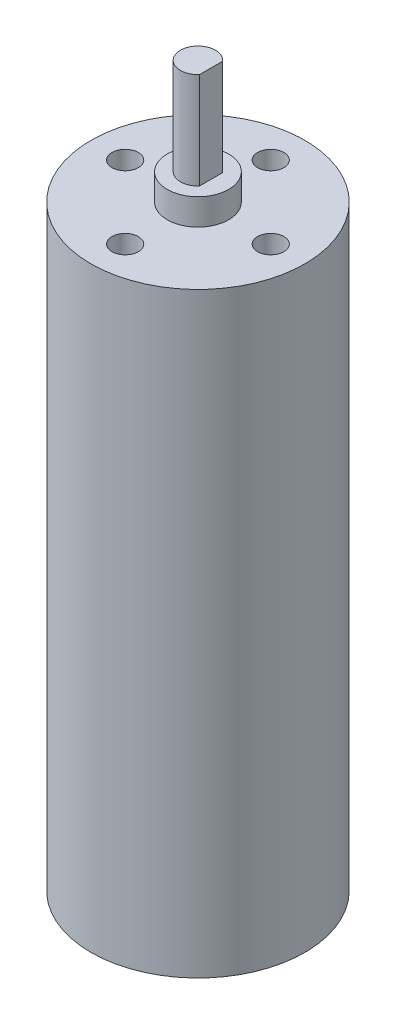
from build123d import *

# Parameters (mm, degrees)
SKETCH1_R           = 12.2
BOSS_EXTRUDE1_DEPTH = 47
SKETCH2_R           = 12.2
BOSS_EXTRUDE3_DEPTH = 21
SKETCH3_R           = 3.5
BOSS_EXTRUDE4_DEPTH = 3
BOSS_EXTRUDE5_DEPTH = 11
SKETCH6_R           = 1
CUT_EXTRUDE1_DEPTH  = 10
SKETCH5_W           = 0.205128205
SKETCH5_H           = 2
SKETCH5_W_2         = 0.820512821
SKETCH5_H_2         = 0.205128205
CUT_EXTRUDE2_DEPTH  = 4
SKETCH7_R           = 1.5
CUT_EXTRUDE3_DEPTH  = 10


with BuildPart() as part:
    # Sketch1 → Boss-Extrude1 (new body)
    with BuildSketch(Plane(origin=(0, 0, 0), x_dir=(1, 0, 0), z_dir=(0, 1, 0))):
        Circle(SKETCH1_R)
    extrude(amount=BOSS_EXTRUDE1_DEPTH)

    # Sketch2 → Boss-Extrude3 (add)
    with BuildSketch(Plane(origin=(0, 47, 0), x_dir=(1, 0, 0), z_dir=(0, 1, 0))):
        Circle(SKETCH2_R)
    extrude(amount=BOSS_EXTRUDE3_DEPTH)

    # Sketch3 → Boss-Extrude4 (add)
    with BuildSketch(Plane(origin=(0, 68, 0), x_dir=(1, 0, 0), z_dir=(0, 1, 0))):
        Circle(SKETCH3_R)
    extrude(amount=BOSS_EXTRUDE4_DEPTH)

    # Sketch4 → Boss-Extrude5 (add)
    with BuildSketch(Plane(origin=(0, 71, 0), x_dir=(1, 0, 0), z_dir=(0, 1, 0))):
        with BuildLine():
            Line((1.5, 1.322875656), (1.5, -1.322875656))
            ThreePointArc((1.5, -1.322875656), (-2, 0), (1.5, 1.322875656))
        make_face()
    extrude(amount=BOSS_EXTRUDE5_DEPTH)

    # Sketch6 → Cut-Extrude1 (cut)
    with BuildSketch(Plane.XZ):
        with Locations((8.05, -5.4)):
            Circle(SKETCH6_R)
        with Locations((-8.05, -5.4)):
            Circle(SKETCH6_R)
    extrude(amount=-CUT_EXTRUDE1_DEPTH, mode=Mode.SUBTRACT)

    # Sketch5 → Cut-Extrude2 (cut)
    with BuildSketch(Plane(origin=(0, 0, 0), x_dir=(-1, 0, 0), z_dir=(0, -1, 0))):
        Polygon((-5.489053151, 2.662817333), (-5.489053151, 2.867945538), (-4.309565971, 2.867945538), (-4.309565971, 2.662817333), (-4.796745458, 2.662817333), (-4.796745458, 0.867945538), (-5.001873664, 0.867945538), (-5.001873664, 2.662817333), align=None)
        with BuildLine():
            Line((-4.207001869, 1.253762846), (-4.02390892, 1.355125026))
            add(Edge.make_bspline(
                [(-4.02390892, 1.355125026), (-4.00757404, 1.328748463), (-3.97615137, 1.278009063), (-3.922967763, 1.210209739), (-3.868503424, 1.152337663), (-3.812101869, 1.104583208), (-3.753255614, 1.067719354), (-3.69243044, 1.04120601), (-3.629472854, 1.024757128), (-3.586638606, 1.022781602), (-3.565174946, 1.021791692)],
                knots=[0, 0, 0, 0, 9.3015e-05, 0.000178929, 0.000257994, 0.000331092, 0.000400017, 0.000465513, 0.000529548, 0.000593862, 0.000593862, 0.000593862, 0.000593862], degree=3))
            add(Edge.make_bspline(
                [(-3.565174946, 1.021791692), (-3.546840813, 1.02228305), (-3.510489496, 1.023257271), (-3.457037672, 1.032494643), (-3.405222036, 1.046834261), (-3.356012331, 1.067289864), (-3.310024333, 1.092095665), (-3.269411625, 1.121717873), (-3.234731505, 1.155451893), (-3.2062716, 1.192804361), (-3.183837681, 1.232786754), (-3.16770717, 1.274321993), (-3.157501468, 1.317107846), (-3.156316586, 1.346121299), (-3.155719817, 1.360734)],
                knots=[0, 0, 0, 0, 5.4959e-05, 0.000108969, 0.00016224, 0.000215958, 0.000268492, 0.000318656, 0.000366253, 0.000413129, 0.000459048, 0.000503316, 0.000546469, 0.000590256, 0.000590256, 0.000590256, 0.000590256], degree=3))
            add(Edge.make_bspline(
                [(-3.155719817, 1.360734), (-3.156709907, 1.377385892), (-3.158723986, 1.411259833), (-3.173450394, 1.46137748), (-3.197601716, 1.510848096), (-3.219842045, 1.541212338), (-3.231440971, 1.557048103)],
                knots=[0, 0, 0, 0, 4.9912e-05, 0.000101532, 0.000155466, 0.000214252, 0.000214252, 0.000214252, 0.000214252], degree=3))
            add(Edge.make_bspline(
                [(-3.231440971, 1.557048103), (-3.240920156, 1.568519083), (-3.260871869, 1.592663114), (-3.295240889, 1.628286348), (-3.33514499, 1.665494867), (-3.380204236, 1.704657296), (-3.431043523, 1.744994445), (-3.48668485, 1.787599611), (-3.548042649, 1.831642563), (-3.59127487, 1.860843513), (-3.61365251, 1.875958359)],
                knots=[0, 0, 0, 0, 4.463e-05, 9.3936e-05, 0.000148356, 0.000208282, 0.000272979, 0.000343013, 0.000418509, 0.000499519, 0.000499519, 0.000499519, 0.000499519], degree=3))
            add(Edge.make_bspline(
                [(-3.61365251, 1.875958359), (-3.635902885, 1.890931948), (-3.678414397, 1.919540451), (-3.737889071, 1.962258064), (-3.791371287, 2.000820692), (-3.837930372, 2.03674063), (-3.878270716, 2.068749896), (-3.91193207, 2.097765097), (-3.938878523, 2.123548), (-3.953885439, 2.14043103), (-3.960607638, 2.147993615)],
                knots=[0, 0, 0, 0, 8.0453e-05, 0.000153713, 0.000219665, 0.000278242, 0.000330112, 0.000374134, 0.000411533, 0.000441879, 0.000441879, 0.000441879, 0.000441879], degree=3))
            add(Edge.make_bspline(
                [(-3.960607638, 2.147993615), (-3.970005636, 2.159743769), (-3.988430446, 2.182779989), (-4.012513879, 2.219099069), (-4.033359706, 2.256003604), (-4.049332781, 2.294141743), (-4.06313621, 2.332468551), (-4.072244012, 2.371861828), (-4.077436229, 2.412010082), (-4.078342814, 2.438977996), (-4.07879674, 2.452480795)],
                knots=[0, 0, 0, 0, 4.5118e-05, 8.8454e-05, 0.000130597, 0.000172052, 0.000212344, 0.000252673, 0.000293074, 0.000333589, 0.000333589, 0.000333589, 0.000333589], degree=3))
            add(Edge.make_bspline(
                [(-4.07879674, 2.452480795), (-4.077936457, 2.473645801), (-4.07623246, 2.515568163), (-4.06302578, 2.576863694), (-4.041553667, 2.63524092), (-4.011893175, 2.69027377), (-3.973951553, 2.740869175), (-3.929043756, 2.786342303), (-3.876730982, 2.825573322), (-3.818623165, 2.858986725), (-3.755421096, 2.885521792), (-3.689181895, 2.905525845), (-3.619910334, 2.916764366), (-3.572959054, 2.918398761), (-3.549149305, 2.91922759)],
                knots=[0, 0, 0, 0, 6.3455e-05, 0.000125687, 0.000187163, 0.000249546, 0.000312527, 0.000376269, 0.000440613, 0.000508097, 0.000576854, 0.000645813, 0.000715235, 0.000786662, 0.000786662, 0.000786662, 0.000786662], degree=3))
            add(Edge.make_bspline(
                [(-3.549149305, 2.91922759), (-3.523851672, 2.918536612), (-3.473590897, 2.917163794), (-3.399808929, 2.90376415), (-3.32840691, 2.882851629), (-3.271033302, 2.858297667), (-3.22580922, 2.834081615), (-3.191599668, 2.811668995), (-3.15686913, 2.785910249), (-3.121132475, 2.757255492), (-3.085477122, 2.724543472), (-3.049413455, 2.688304504), (-3.012616916, 2.648789697), (-2.988552475, 2.620704976), (-2.976232638, 2.606326949)],
                knots=[0, 0, 0, 0, 7.5827e-05, 0.000150652, 0.000224178, 0.000298669, 0.00033739, 0.000377952, 0.000421223, 0.000467087, 0.000515301, 0.000566294, 0.00062044, 0.000677238, 0.000677238, 0.000677238, 0.000677238], degree=3))
            Line((-2.976232638, 2.606326949), (-3.151713407, 2.483330154))
            add(Edge.make_bspline(
                [(-3.151713407, 2.483330154), (-3.16208107, 2.494593355), (-3.182170594, 2.516418171), (-3.212079487, 2.547303063), (-3.241088274, 2.57493374), (-3.26854246, 2.600064926), (-3.295508373, 2.621401501), (-3.320635384, 2.640695965), (-3.345118337, 2.656094148), (-3.375505761, 2.6734381), (-3.414234001, 2.68973478), (-3.462324209, 2.703917752), (-3.51251753, 2.712510594), (-3.546712613, 2.713566435), (-3.563973022, 2.714099385)],
                knots=[0, 0, 0, 0, 4.5925e-05, 8.899e-05, 0.000128944, 0.000166109, 0.000200585, 0.000232075, 0.000261082, 0.000287271, 0.000336985, 0.00038668, 0.000437462, 0.000489221, 0.000489221, 0.000489221, 0.000489221], degree=3))
            add(Edge.make_bspline(
                [(-3.563973022, 2.714099385), (-3.585830928, 2.713410433), (-3.627906232, 2.712084239), (-3.687644911, 2.697544865), (-3.741369278, 2.674689503), (-3.780306268, 2.647521225), (-3.807568664, 2.622729611), (-3.824933859, 2.602580604), (-3.840469752, 2.582053294), (-3.85233926, 2.559582857), (-3.862279685, 2.536516445), (-3.868303574, 2.511979665), (-3.87324636, 2.486865424), (-3.873527001, 2.469601093), (-3.873668535, 2.460894256)],
                knots=[0, 0, 0, 0, 6.5453e-05, 0.000125994, 0.000183231, 0.000239685, 0.000267472, 0.00029359, 0.000319393, 0.000344494, 0.000369642, 0.00039452, 0.000420142, 0.000446212, 0.000446212, 0.000446212, 0.000446212], degree=3))
            add(Edge.make_bspline(
                [(-3.873668535, 2.460894256), (-3.873257484, 2.450185515), (-3.872434998, 2.428758035), (-3.866549206, 2.39691846), (-3.857377518, 2.365405022), (-3.843841006, 2.334045541), (-3.825465777, 2.302099485), (-3.800574025, 2.269793822), (-3.769905878, 2.236022522), (-3.746564049, 2.214067501), (-3.734245458, 2.202480795)],
                knots=[0, 0, 0, 0, 3.2114e-05, 6.4258e-05, 9.6838e-05, 0.000130401, 0.000166479, 0.000207104, 0.000252488, 0.000303205, 0.000303205, 0.000303205, 0.000303205], degree=3))
            add(Edge.make_bspline(
                [(-3.734245458, 2.202480795), (-3.729602931, 2.198568442), (-3.718545979, 2.189250521), (-3.698359555, 2.174198318), (-3.671988412, 2.15518693), (-3.639487304, 2.132282696), (-3.60092168, 2.10520124), (-3.555936848, 2.074977167), (-3.50504098, 2.040346569), (-3.468904777, 2.01615727), (-3.44979033, 2.003362205)],
                knots=[0, 0, 0, 0, 1.821e-05, 4.3371e-05, 7.5508e-05, 0.000115748, 0.00016265, 0.000216877, 0.000278327, 0.000347332, 0.000347332, 0.000347332, 0.000347332], degree=3))
            add(Edge.make_bspline(
                [(-3.44979033, 2.003362205), (-3.426725948, 1.987604009), (-3.382200651, 1.957183149), (-3.319088673, 1.910844244), (-3.261332298, 1.866164879), (-3.209321993, 1.822621642), (-3.162927463, 1.780520034), (-3.1223847, 1.739502634), (-3.086849607, 1.700167496), (-3.057364439, 1.66117229), (-3.032242465, 1.62306249), (-3.010499861, 1.585361392), (-2.992006364, 1.547622524), (-2.976644286, 1.509948223), (-2.96479042, 1.47204077), (-2.957162608, 1.433997774), (-2.951359966, 1.396032038), (-2.9508479, 1.370638798), (-2.950591612, 1.357929513)],
                knots=[0, 0, 0, 0, 8.3795e-05, 0.000161765, 0.000234853, 0.000302822, 0.000365211, 0.000422721, 0.000475789, 0.000524107, 0.000569222, 0.000612654, 0.000654582, 0.000695203, 0.000734615, 0.00077351, 0.000811528, 0.000849623, 0.000849623, 0.000849623, 0.000849623], degree=3))
            add(Edge.make_bspline(
                [(-2.950591612, 1.357929513), (-2.951108536, 1.339997587), (-2.952132763, 1.304467495), (-2.960976163, 1.252267275), (-2.974373708, 1.201586064), (-2.994438854, 1.153026771), (-3.01922216, 1.105867843), (-3.049955656, 1.060796509), (-3.086378835, 1.017761198), (-3.127589905, 0.977069039), (-3.172594501, 0.939429114), (-3.220672889, 0.906648221), (-3.271114081, 0.87857096), (-3.324175411, 0.856344806), (-3.379500852, 0.838475063), (-3.437169088, 0.825770705), (-3.497380422, 0.817876611), (-3.538307207, 0.817073029), (-3.55916533, 0.816663487)],
                knots=[0, 0, 0, 0, 5.3759e-05, 0.000106518, 0.000158417, 0.000210719, 0.000263769, 0.000317996, 0.000374013, 0.000432656, 0.000491544, 0.000549774, 0.000606977, 0.000664424, 0.000722074, 0.000781173, 0.000841352, 0.000903898, 0.000903898, 0.000903898, 0.000903898], degree=3))
            add(Edge.make_bspline(
                [(-3.55916533, 0.816663487), (-3.575339499, 0.8169457), (-3.607226613, 0.817502077), (-3.654425777, 0.822703075), (-3.700594099, 0.82992423), (-3.745465183, 0.841451656), (-3.789420117, 0.855439842), (-3.832219024, 0.872552335), (-3.873736078, 0.893290781), (-3.914341066, 0.916839), (-3.953992358, 0.944440386), (-3.992711681, 0.97602594), (-4.030587376, 1.011936092), (-4.067298585, 1.052257668), (-4.103917237, 1.096324882), (-4.139428776, 1.144796692), (-4.174016142, 1.197594456), (-4.195808466, 1.234702621), (-4.207001869, 1.253762846)],
                knots=[0, 0, 0, 0, 4.8504e-05, 9.5625e-05, 0.000142323, 0.000188576, 0.000234442, 0.000280643, 0.00032669, 0.000373553, 0.000421342, 0.000471462, 0.000523325, 0.000577765, 0.000634961, 0.00069514, 0.000757923, 0.000824228, 0.000824228, 0.000824228, 0.000824228], degree=3))
        make_face()
        with Locations((-2.412130074, 1.867945538)):
            Rectangle(SKETCH5_W, SKETCH5_H)
        Polygon((-1.822386484, 0.867945538), (-1.822386484, 2.867945538), (-1.779117253, 2.867945538), (-0.309565971, 1.319067333), (-0.309565971, 2.867945538), (-0.104437766, 2.867945538), (-0.104437766, 0.867945538), (-0.151312766, 0.867945538), (-1.617258279, 2.412817333), (-1.617258279, 0.867945538), align=None)
        Polygon((0.254536593, 2.867945538), (0.494520567, 2.867945538), (1.049408388, 2.027400667), (1.604296208, 2.867945538), (1.844280183, 2.867945538), (1.15197249, 1.818666692), (1.15197249, 0.867945538), (0.946844285, 0.867945538), (0.946844285, 1.818666692), align=None)
        Polygon((-5.489053151, -1.670516), (-5.489053151, -1.465387795), (-4.309565971, -1.465387795), (-4.309565971, -1.670516), (-4.796745458, -1.670516), (-4.796745458, -3.465387795), (-5.001873664, -3.465387795), (-5.001873664, -1.670516), align=None)
        with BuildLine():
            Line((-4.207001869, -3.079570487), (-4.02390892, -2.978208308))
            add(Edge.make_bspline(
                [(-4.02390892, -2.978208308), (-4.00757404, -3.00458487), (-3.97615137, -3.05532427), (-3.922967763, -3.123123594), (-3.868503424, -3.18099567), (-3.812101869, -3.228750126), (-3.753255614, -3.265613979), (-3.69243044, -3.292127324), (-3.629472854, -3.308576205), (-3.586638606, -3.310551732), (-3.565174946, -3.311541641)],
                knots=[0, 0, 0, 0, 9.3015e-05, 0.000178929, 0.000257994, 0.000331092, 0.000400017, 0.000465513, 0.000529548, 0.000593862, 0.000593862, 0.000593862, 0.000593862], degree=3))
            add(Edge.make_bspline(
                [(-3.565174946, -3.311541641), (-3.546840813, -3.311050283), (-3.510489496, -3.310076062), (-3.457037672, -3.30083869), (-3.405222036, -3.286499073), (-3.356012331, -3.266043469), (-3.310024333, -3.241237668), (-3.269411625, -3.211615461), (-3.234731505, -3.177881441), (-3.2062716, -3.140528972), (-3.183837681, -3.10054658), (-3.16770717, -3.05901134), (-3.157501468, -3.016225487), (-3.156316586, -2.987212035), (-3.155719817, -2.972599333)],
                knots=[0, 0, 0, 0, 5.4959e-05, 0.000108969, 0.00016224, 0.000215958, 0.000268492, 0.000318656, 0.000366253, 0.000413129, 0.000459048, 0.000503316, 0.000546469, 0.000590256, 0.000590256, 0.000590256, 0.000590256], degree=3))
            add(Edge.make_bspline(
                [(-3.155719817, -2.972599333), (-3.156709907, -2.955947442), (-3.158723986, -2.9220735), (-3.173450394, -2.871955854), (-3.197601716, -2.822485238), (-3.219842045, -2.792120996), (-3.231440971, -2.776285231)],
                knots=[0, 0, 0, 0, 4.9912e-05, 0.000101532, 0.000155466, 0.000214252, 0.000214252, 0.000214252, 0.000214252], degree=3))
            add(Edge.make_bspline(
                [(-3.231440971, -2.776285231), (-3.240920156, -2.76481425), (-3.260871869, -2.740670219), (-3.295240889, -2.705046985), (-3.33514499, -2.667838466), (-3.380204236, -2.628676037), (-3.431043523, -2.588338888), (-3.48668485, -2.545733723), (-3.548042649, -2.501690771), (-3.59127487, -2.47248982), (-3.61365251, -2.457374974)],
                knots=[0, 0, 0, 0, 4.463e-05, 9.3936e-05, 0.000148356, 0.000208282, 0.000272979, 0.000343013, 0.000418509, 0.000499519, 0.000499519, 0.000499519, 0.000499519], degree=3))
            add(Edge.make_bspline(
                [(-3.61365251, -2.457374974), (-3.635902885, -2.442401385), (-3.678414397, -2.413792883), (-3.737889071, -2.37107527), (-3.791371287, -2.332512642), (-3.837930372, -2.296592703), (-3.878270716, -2.264583437), (-3.91193207, -2.235568236), (-3.938878523, -2.209785333), (-3.953885439, -2.192902303), (-3.960607638, -2.185339718)],
                knots=[0, 0, 0, 0, 8.0453e-05, 0.000153713, 0.000219665, 0.000278242, 0.000330112, 0.000374134, 0.000411533, 0.000441879, 0.000441879, 0.000441879, 0.000441879], degree=3))
            add(Edge.make_bspline(
                [(-3.960607638, -2.185339718), (-3.970005636, -2.173589564), (-3.988430446, -2.150553344), (-4.012513879, -2.114234264), (-4.033359706, -2.077329729), (-4.049332781, -2.03919159), (-4.06313621, -2.000864782), (-4.072244012, -1.961471505), (-4.077436229, -1.921323251), (-4.078342814, -1.894355338), (-4.07879674, -1.880852538)],
                knots=[0, 0, 0, 0, 4.5118e-05, 8.8454e-05, 0.000130597, 0.000172052, 0.000212344, 0.000252673, 0.000293074, 0.000333589, 0.000333589, 0.000333589, 0.000333589], degree=3))
            add(Edge.make_bspline(
                [(-4.07879674, -1.880852538), (-4.077936457, -1.859687532), (-4.07623246, -1.81776517), (-4.06302578, -1.756469639), (-4.041553667, -1.698092413), (-4.011893175, -1.643059564), (-3.973951553, -1.592464159), (-3.929043756, -1.54699103), (-3.876730982, -1.507760012), (-3.818623165, -1.474346608), (-3.755421096, -1.447811541), (-3.689181895, -1.427807488), (-3.619910334, -1.416568968), (-3.572959054, -1.414934572), (-3.549149305, -1.414105744)],
                knots=[0, 0, 0, 0, 6.3455e-05, 0.000125687, 0.000187163, 0.000249546, 0.000312527, 0.000376269, 0.000440613, 0.000508097, 0.000576854, 0.000645813, 0.000715235, 0.000786662, 0.000786662, 0.000786662, 0.000786662], degree=3))
            add(Edge.make_bspline(
                [(-3.549149305, -1.414105744), (-3.523851672, -1.414796721), (-3.473590897, -1.41616954), (-3.399808929, -1.429569183), (-3.32840691, -1.450481704), (-3.271033302, -1.475035667), (-3.22580922, -1.499251718), (-3.191599668, -1.521664339), (-3.15686913, -1.547423084), (-3.121132475, -1.576077842), (-3.085477122, -1.608789861), (-3.049413455, -1.645028829), (-3.012616916, -1.684543636), (-2.988552475, -1.712628357), (-2.976232638, -1.727006385)],
                knots=[0, 0, 0, 0, 7.5827e-05, 0.000150652, 0.000224178, 0.000298669, 0.00033739, 0.000377952, 0.000421223, 0.000467087, 0.000515301, 0.000566294, 0.00062044, 0.000677238, 0.000677238, 0.000677238, 0.000677238], degree=3))
            Line((-2.976232638, -1.727006385), (-3.151713407, -1.85000318))
            add(Edge.make_bspline(
                [(-3.151713407, -1.85000318), (-3.16208107, -1.838739979), (-3.182170594, -1.816915163), (-3.212079487, -1.786030271), (-3.241088274, -1.758399594), (-3.26854246, -1.733268407), (-3.295508373, -1.711931832), (-3.320635384, -1.692637369), (-3.345118337, -1.677239185), (-3.375505761, -1.659895233), (-3.414234001, -1.643598553), (-3.462324209, -1.629415581), (-3.51251753, -1.620822739), (-3.546712613, -1.619766898), (-3.563973022, -1.619233949)],
                knots=[0, 0, 0, 0, 4.5925e-05, 8.899e-05, 0.000128944, 0.000166109, 0.000200585, 0.000232075, 0.000261082, 0.000287271, 0.000336985, 0.00038668, 0.000437462, 0.000489221, 0.000489221, 0.000489221, 0.000489221], degree=3))
            add(Edge.make_bspline(
                [(-3.563973022, -1.619233949), (-3.585830928, -1.6199229), (-3.627906232, -1.621249094), (-3.687644911, -1.635788468), (-3.741369278, -1.658643831), (-3.780306268, -1.685812108), (-3.807568664, -1.710603722), (-3.824933859, -1.730752729), (-3.840469752, -1.751280039), (-3.85233926, -1.773750476), (-3.862279685, -1.796816889), (-3.868303574, -1.821353668), (-3.87324636, -1.846467909), (-3.873527001, -1.86373224), (-3.873668535, -1.872439077)],
                knots=[0, 0, 0, 0, 6.5453e-05, 0.000125994, 0.000183231, 0.000239685, 0.000267472, 0.00029359, 0.000319393, 0.000344494, 0.000369642, 0.00039452, 0.000420142, 0.000446212, 0.000446212, 0.000446212, 0.000446212], degree=3))
            add(Edge.make_bspline(
                [(-3.873668535, -1.872439077), (-3.873257484, -1.883147819), (-3.872434998, -1.904575298), (-3.866549206, -1.936414873), (-3.857377518, -1.967928311), (-3.843841006, -1.999287793), (-3.825465777, -2.031233848), (-3.800574025, -2.063539511), (-3.769905878, -2.097310811), (-3.746564049, -2.119265832), (-3.734245458, -2.130852538)],
                knots=[0, 0, 0, 0, 3.2114e-05, 6.4258e-05, 9.6838e-05, 0.000130401, 0.000166479, 0.000207104, 0.000252488, 0.000303205, 0.000303205, 0.000303205, 0.000303205], degree=3))
            add(Edge.make_bspline(
                [(-3.734245458, -2.130852538), (-3.729602931, -2.134764891), (-3.718545979, -2.144082812), (-3.698359555, -2.159135015), (-3.671988412, -2.178146404), (-3.639487304, -2.201050637), (-3.60092168, -2.228132093), (-3.555936848, -2.258356166), (-3.50504098, -2.292986764), (-3.468904777, -2.317176063), (-3.44979033, -2.329971128)],
                knots=[0, 0, 0, 0, 1.821e-05, 4.3371e-05, 7.5508e-05, 0.000115748, 0.00016265, 0.000216877, 0.000278327, 0.000347332, 0.000347332, 0.000347332, 0.000347332], degree=3))
            add(Edge.make_bspline(
                [(-3.44979033, -2.329971128), (-3.426725948, -2.345729324), (-3.382200651, -2.376150184), (-3.319088673, -2.42248909), (-3.261332298, -2.467168454), (-3.209321993, -2.510711691), (-3.162927463, -2.552813299), (-3.1223847, -2.593830699), (-3.086849607, -2.633165837), (-3.057364439, -2.672161043), (-3.032242465, -2.710270844), (-3.010499861, -2.747971941), (-2.992006364, -2.785710809), (-2.976644286, -2.82338511), (-2.96479042, -2.861292563), (-2.957162608, -2.899335559), (-2.951359966, -2.937301295), (-2.9508479, -2.962694536), (-2.950591612, -2.975403821)],
                knots=[0, 0, 0, 0, 8.3795e-05, 0.000161765, 0.000234853, 0.000302822, 0.000365211, 0.000422721, 0.000475789, 0.000524107, 0.000569222, 0.000612654, 0.000654582, 0.000695203, 0.000734615, 0.00077351, 0.000811528, 0.000849623, 0.000849623, 0.000849623, 0.000849623], degree=3))
            add(Edge.make_bspline(
                [(-2.950591612, -2.975403821), (-2.951108536, -2.993335746), (-2.952132763, -3.028865838), (-2.960976163, -3.081066059), (-2.974373708, -3.131747269), (-2.994438854, -3.180306562), (-3.01922216, -3.22746549), (-3.049955656, -3.272536825), (-3.086378835, -3.315572136), (-3.127589905, -3.356264295), (-3.172594501, -3.393904219), (-3.220672889, -3.426685112), (-3.271114081, -3.454762373), (-3.324175411, -3.476988528), (-3.379500852, -3.49485827), (-3.437169088, -3.507562628), (-3.497380422, -3.515456722), (-3.538307207, -3.516260305), (-3.55916533, -3.516669846)],
                knots=[0, 0, 0, 0, 5.3759e-05, 0.000106518, 0.000158417, 0.000210719, 0.000263769, 0.000317996, 0.000374013, 0.000432656, 0.000491544, 0.000549774, 0.000606977, 0.000664424, 0.000722074, 0.000781173, 0.000841352, 0.000903898, 0.000903898, 0.000903898, 0.000903898], degree=3))
            add(Edge.make_bspline(
                [(-3.55916533, -3.516669846), (-3.575339499, -3.516387634), (-3.607226613, -3.515831257), (-3.654425777, -3.510630259), (-3.700594099, -3.503409103), (-3.745465183, -3.491881677), (-3.789420117, -3.477893492), (-3.832219024, -3.460780998), (-3.873736078, -3.440042552), (-3.914341066, -3.416494333), (-3.953992358, -3.388892948), (-3.992711681, -3.357307393), (-4.030587376, -3.321397242), (-4.067298585, -3.281075665), (-4.103917237, -3.237008451), (-4.139428776, -3.188536641), (-4.174016142, -3.135738877), (-4.195808466, -3.098630713), (-4.207001869, -3.079570487)],
                knots=[0, 0, 0, 0, 4.8504e-05, 9.5625e-05, 0.000142323, 0.000188576, 0.000234442, 0.000280643, 0.00032669, 0.000373553, 0.000421342, 0.000471462, 0.000523325, 0.000577765, 0.000634961, 0.00069514, 0.000757923, 0.000824228, 0.000824228, 0.000824228, 0.000824228], degree=3))
        make_face()
        with Locations((-2.283924945, -2.696157026)):
            Rectangle(SKETCH5_W_2, SKETCH5_H_2)
        with BuildLine():
            Line((-1.386489048, -2.08077241), (-1.591617253, -2.08077241))
            add(Edge.make_bspline(
                [(-1.591617253, -2.08077241), (-1.590329635, -2.056958171), (-1.587799011, -2.010154791), (-1.576400012, -1.941848582), (-1.559072103, -1.876794999), (-1.535982575, -1.814912565), (-1.506239876, -1.7565065), (-1.471566247, -1.700784096), (-1.429799725, -1.648972972), (-1.38272479, -1.600818564), (-1.331439896, -1.556994793), (-1.276674694, -1.518542065), (-1.218648542, -1.486535033), (-1.157982018, -1.459838475), (-1.094159736, -1.439418532), (-1.027535957, -1.424611114), (-0.957786281, -1.415549238), (-0.910287944, -1.414592953), (-0.886088407, -1.414105744)],
                knots=[0, 0, 0, 0, 7.1504e-05, 0.000140531, 0.000207295, 0.000273224, 0.000338264, 0.000403623, 0.000469759, 0.000537472, 0.000605393, 0.000671857, 0.000737855, 0.000803878, 0.000870395, 0.000938534, 0.001008403, 0.001080973, 0.001080973, 0.001080973, 0.001080973], degree=3))
            add(Edge.make_bspline(
                [(-0.886088407, -1.414105744), (-0.862291602, -1.414619088), (-0.815745026, -1.41562319), (-0.747618672, -1.424227358), (-0.683023157, -1.438249628), (-0.621638498, -1.457292028), (-0.56405644, -1.482709303), (-0.510157401, -1.513897987), (-0.459148802, -1.549914701), (-0.412885654, -1.592057539), (-0.370699979, -1.637156108), (-0.333870591, -1.684947005), (-0.302358613, -1.73453099), (-0.277173423, -1.786704406), (-0.256839666, -1.840369723), (-0.242873841, -1.896304882), (-0.234201561, -1.954163208), (-0.233166712, -1.993535388), (-0.232642894, -2.013464718)],
                knots=[0, 0, 0, 0, 7.1369e-05, 0.000139598, 0.000205608, 0.00026947, 0.000332075, 0.000393993, 0.000456029, 0.000519013, 0.000581379, 0.00064108, 0.000699771, 0.000757287, 0.000814589, 0.000871628, 0.00092993, 0.000989692, 0.000989692, 0.000989692, 0.000989692], degree=3))
            add(Edge.make_bspline(
                [(-0.232642894, -2.013464718), (-0.233731149, -2.041458589), (-0.23589535, -2.097129685), (-0.253025671, -2.179059212), (-0.280292522, -2.258394615), (-0.313036661, -2.322021443), (-0.34548246, -2.373423918), (-0.375391169, -2.415510751), (-0.410256409, -2.460973888), (-0.449948021, -2.510091734), (-0.495374808, -2.561844922), (-0.54556829, -2.617424178), (-0.601176366, -2.676032019), (-0.640305147, -2.715977383), (-0.66052751, -2.736621769)],
                knots=[0, 0, 0, 0, 8.3922e-05, 0.000166894, 0.000250011, 0.000334941, 0.000380849, 0.000432313, 0.000489767, 0.000552714, 0.000621723, 0.000696321, 0.000777375, 0.000864071, 0.000864071, 0.000864071, 0.000864071], degree=3))
            Line((-0.66052751, -2.736621769), (-1.18416533, -3.26025959))
            Line((-1.18416533, -3.26025959), (-0.207001869, -3.26025959))
            Line((-0.207001869, -3.26025959), (-0.207001869, -3.465387795))
            Line((-0.207001869, -3.465387795), (-1.66854033, -3.465387795))
            Line((-1.66854033, -3.465387795), (-0.841216612, -2.637663436))
            add(Edge.make_bspline(
                [(-0.841216612, -2.637663436), (-0.8211545, -2.617929338), (-0.782578989, -2.579984532), (-0.72764731, -2.524988235), (-0.678743802, -2.473458594), (-0.634879733, -2.426214953), (-0.596574795, -2.382878402), (-0.563812202, -2.343347945), (-0.536507123, -2.307915357), (-0.507790981, -2.266185741), (-0.479646306, -2.215562952), (-0.455207498, -2.153570195), (-0.440606807, -2.089593245), (-0.438719429, -2.046390345), (-0.437771099, -2.024682667)],
                knots=[0, 0, 0, 0, 8.4424e-05, 0.000162331, 0.000233175, 0.000297534, 0.000355726, 0.000406665, 0.000451538, 0.000489876, 0.000558559, 0.000624775, 0.00068922, 0.000754302, 0.000754302, 0.000754302, 0.000754302], degree=3))
            add(Edge.make_bspline(
                [(-0.437771099, -2.024682667), (-0.438107615, -2.011033496), (-0.438771339, -1.984112721), (-0.445493568, -1.944630841), (-0.455950984, -1.906635923), (-0.470438966, -1.869886678), (-0.489260143, -1.834666754), (-0.512496279, -1.801159283), (-0.539498255, -1.768888566), (-0.570406978, -1.73850116), (-0.604289308, -1.710566977), (-0.640380476, -1.685920217), (-0.678657948, -1.665560332), (-0.71857738, -1.648580743), (-0.760388056, -1.635219042), (-0.804187294, -1.626235898), (-0.84974098, -1.62040196), (-0.88072816, -1.619628004), (-0.896505074, -1.619233949)],
                knots=[0, 0, 0, 0, 4.0914e-05, 8.0697e-05, 0.000119771, 0.000158979, 0.000198949, 0.000239288, 0.000281096, 0.000325007, 0.000369123, 0.000412683, 0.000455881, 0.000498967, 0.000542681, 0.000587312, 0.000632931, 0.000680249, 0.000680249, 0.000680249, 0.000680249], degree=3))
            add(Edge.make_bspline(
                [(-0.896505074, -1.619233949), (-0.913079711, -1.61963897), (-0.945524714, -1.620431803), (-0.993147222, -1.626057814), (-1.038557061, -1.635752941), (-1.081906141, -1.648899797), (-1.123158416, -1.66580883), (-1.162232294, -1.686745709), (-1.199115281, -1.711778756), (-1.233890984, -1.740007944), (-1.265723523, -1.771709634), (-1.293841662, -1.806917696), (-1.318796565, -1.844883497), (-1.339688909, -1.886200031), (-1.356997724, -1.930478971), (-1.370309789, -1.977911441), (-1.381183042, -2.028168841), (-1.384692286, -2.06295937), (-1.386489048, -2.08077241)],
                knots=[0, 0, 0, 0, 4.972e-05, 9.7327e-05, 0.000143609, 0.000188853, 0.000233048, 0.000277142, 0.000321589, 0.000366579, 0.00041134, 0.000456077, 0.000501527, 0.000547396, 0.000594714, 0.000643913, 0.000695065, 0.000748735, 0.000748735, 0.000748735, 0.000748735], degree=3))
        make_face()
        with BuildLine():
            Line((1.357100695, -1.465387795), (1.357100695, -1.670516))
            Line((1.357100695, -1.670516), (0.64796608, -1.670516))
            Line((0.64796608, -1.670516), (0.525770567, -2.198961513))
            add(Edge.make_bspline(
                [(0.525770567, -2.198961513), (0.547994105, -2.192624224), (0.591057519, -2.180344214), (0.654853933, -2.167877125), (0.715157541, -2.158987977), (0.754373511, -2.158117217), (0.773366721, -2.157695487)],
                knots=[0, 0, 0, 0, 6.9294e-05, 0.000134273, 0.000194901, 0.000251843, 0.000251843, 0.000251843, 0.000251843], degree=3))
            add(Edge.make_bspline(
                [(0.773366721, -2.157695487), (0.796766758, -2.158181965), (0.842804523, -2.159139072), (0.910122214, -2.168218606), (0.974374684, -2.182621316), (1.035450025, -2.202681293), (1.093598451, -2.228312112), (1.14827865, -2.260390304), (1.200279823, -2.297549321), (1.248032477, -2.340882539), (1.291412126, -2.38827853), (1.330066631, -2.43893377), (1.361887063, -2.493366885), (1.388964013, -2.550519335), (1.40855635, -2.611545255), (1.423609404, -2.67538972), (1.432564329, -2.742644879), (1.433531011, -2.788544922), (1.434023772, -2.811942282)],
                knots=[0, 0, 0, 0, 7.0168e-05, 0.000138051, 0.000203365, 0.000267472, 0.000330606, 0.000393619, 0.000457332, 0.000522013, 0.000586667, 0.000649888, 0.000712758, 0.000775494, 0.000839221, 0.000904625, 0.00097211, 0.001042278, 0.001042278, 0.001042278, 0.001042278], degree=3))
            add(Edge.make_bspline(
                [(1.434023772, -2.811942282), (1.433681787, -2.828243657), (1.433002193, -2.860637748), (1.428600841, -2.908709044), (1.420939352, -2.955821287), (1.410193297, -3.001905977), (1.396023215, -3.046802848), (1.379220103, -3.090783976), (1.358980761, -3.133599912), (1.336473908, -3.175565409), (1.31074617, -3.215401973), (1.283148865, -3.253328343), (1.252975735, -3.288515864), (1.220885198, -3.321619988), (1.18632948, -3.351982592), (1.149761124, -3.380240501), (1.110840466, -3.405806435), (1.06987137, -3.429043048), (1.027190411, -3.450006307), (0.982419694, -3.467447875), (0.936465246, -3.48274703), (0.888716384, -3.495307709), (0.839308094, -3.504797557), (0.788190821, -3.511439619), (0.735663413, -3.516226176), (0.700060599, -3.51652064), (0.682020567, -3.516669846)],
                knots=[0, 0, 0, 0, 4.8904e-05, 9.7183e-05, 0.000144672, 0.000191999, 0.00023901, 0.00028581, 0.000333128, 0.000380994, 0.000428561, 0.000475278, 0.000521602, 0.000567499, 0.000613481, 0.000659478, 0.000706037, 0.000753047, 0.000800709, 0.000848547, 0.000897071, 0.000945951, 0.000996552, 0.001047888, 0.001100556, 0.001154656, 0.001154656, 0.001154656, 0.001154656], degree=3))
            add(Edge.make_bspline(
                [(0.682020567, -3.516669846), (0.660492382, -3.516275928), (0.618230278, -3.515502624), (0.556382994, -3.507418747), (0.496899007, -3.495670037), (0.440080222, -3.478321158), (0.385584451, -3.456402172), (0.334242181, -3.428735034), (0.284903753, -3.397092655), (0.238781559, -3.360273822), (0.196034228, -3.319734476), (0.157923317, -3.275597687), (0.123342884, -3.229316433), (0.094910285, -3.179129073), (0.06949647, -3.126932242), (0.049774895, -3.071345386), (0.033841783, -3.013105082), (0.027157705, -2.972940059), (0.023767362, -2.952567282)],
                knots=[0, 0, 0, 0, 6.4548e-05, 0.000126715, 0.000186823, 0.000246265, 0.000304668, 0.000362737, 0.000420968, 0.000480285, 0.000539511, 0.000597439, 0.000655055, 0.000712502, 0.000770205, 0.000829011, 0.000889168, 0.00095109, 0.00095109, 0.00095109, 0.00095109], degree=3))
            Line((0.023767362, -2.952567282), (0.228895567, -2.952567282))
            add(Edge.make_bspline(
                [(0.228895567, -2.952567282), (0.23358286, -2.971643283), (0.242599404, -3.008338153), (0.261985075, -3.059935932), (0.285996839, -3.105887119), (0.314784129, -3.146650204), (0.348712569, -3.182412023), (0.387638129, -3.214164007), (0.431334267, -3.242698514), (0.479725253, -3.266729256), (0.530804156, -3.286912735), (0.584254721, -3.300686823), (0.638688354, -3.310064901), (0.675571072, -3.311048907), (0.694039798, -3.311541641)],
                knots=[0, 0, 0, 0, 5.8893e-05, 0.000113287, 0.0001649, 0.000214035, 0.0002625, 0.00031231, 0.000364427, 0.000418716, 0.000474146, 0.000528858, 0.000584053, 0.000639413, 0.000639413, 0.000639413, 0.000639413], degree=3))
            add(Edge.make_bspline(
                [(0.694039798, -3.311541641), (0.712092876, -3.311077151), (0.747528663, -3.31016542), (0.799662257, -3.303040576), (0.849942505, -3.292099256), (0.898053975, -3.275722994), (0.944755461, -3.255825856), (0.988925814, -3.230390472), (1.031517276, -3.200889096), (1.071443228, -3.167177579), (1.108237061, -3.130192125), (1.140516323, -3.090353029), (1.167798667, -3.048125195), (1.190550853, -3.003819854), (1.207842194, -2.957126994), (1.219631342, -2.908145717), (1.227724914, -2.85708169), (1.228500681, -2.822124333), (1.228895567, -2.804330103)],
                knots=[0, 0, 0, 0, 5.414e-05, 0.000106269, 0.000157591, 0.000208268, 0.000258508, 0.000309643, 0.000360878, 0.000413766, 0.000466176, 0.000517171, 0.00056729, 0.000616742, 0.000666307, 0.000716252, 0.0007677, 0.00082104, 0.00082104, 0.00082104, 0.00082104], degree=3))
            add(Edge.make_bspline(
                [(1.228895567, -2.804330103), (1.228605788, -2.788275186), (1.228037915, -2.756812814), (1.220787476, -2.71096604), (1.210204332, -2.667378138), (1.194792549, -2.626132368), (1.175059325, -2.587251769), (1.151367667, -2.550301613), (1.122625448, -2.516342403), (1.090153496, -2.48468109), (1.054306523, -2.455932161), (1.01516424, -2.430781017), (0.972719823, -2.410235698), (0.927928613, -2.392204622), (0.879841741, -2.379321297), (0.829123006, -2.369542142), (0.775357391, -2.364034268), (0.738522766, -2.363233373), (0.719680824, -2.362823692)],
                knots=[0, 0, 0, 0, 4.8119e-05, 9.4297e-05, 0.000138898, 0.000182507, 0.000226046, 0.000269497, 0.000313868, 0.000359199, 0.000405376, 0.000451498, 0.000498442, 0.000546652, 0.000596127, 0.000647516, 0.000701494, 0.00075802, 0.00075802, 0.00075802, 0.00075802], degree=3))
            add(Edge.make_bspline(
                [(0.719680824, -2.362823692), (0.703243608, -2.363147695), (0.669502083, -2.363812793), (0.617613731, -2.368942635), (0.563196309, -2.376946631), (0.506256457, -2.388257883), (0.446808181, -2.402811134), (0.384806906, -2.420465433), (0.320247505, -2.441271834), (0.276785535, -2.457222414), (0.254536593, -2.465387795)],
                knots=[0, 0, 0, 0, 4.9305e-05, 0.000101211, 0.000156284, 0.00021427, 0.000275294, 0.000339847, 0.000407631, 0.000478726, 0.000478726, 0.000478726, 0.000478726], degree=3))
            Line((0.254536593, -2.465387795), (0.485305824, -1.465387795))
            Line((0.485305824, -1.465387795), (1.357100695, -1.465387795))
        make_face()
        with BuildLine():
            Line((3.869921208, -1.806733949), (3.702853901, -1.952567282))
            add(Edge.make_bspline(
                [(3.702853901, -1.952567282), (3.672990235, -1.926368472), (3.613864423, -1.874498553), (3.518051204, -1.807123074), (3.417745011, -1.749907419), (3.314022686, -1.703066934), (3.209244962, -1.665725079), (3.104898275, -1.639233683), (3.00189155, -1.622220556), (2.933419177, -1.62022198), (2.899568644, -1.619233949)],
                knots=[0, 0, 0, 0, 0.000119114, 0.00023583, 0.000350671, 0.000465064, 0.000576826, 0.000683908, 0.000787717, 0.000889213, 0.000889213, 0.000889213, 0.000889213], degree=3))
            add(Edge.make_bspline(
                [(2.899568644, -1.619233949), (2.878719954, -1.619459434), (2.837344832, -1.619906919), (2.7757221, -1.626032561), (2.714817169, -1.634590009), (2.65461827, -1.647101382), (2.595208758, -1.663124531), (2.536526803, -1.682916491), (2.478521094, -1.70599812), (2.421928276, -1.732880307), (2.367078852, -1.76231807), (2.315133382, -1.794667812), (2.266315851, -1.829616853), (2.221027948, -1.867495099), (2.178496701, -1.907512319), (2.138948321, -1.949961153), (2.103410224, -1.995594982), (2.070565387, -2.042969551), (2.041552122, -2.092055138), (2.015973883, -2.141982476), (1.994838324, -2.192805371), (1.977596926, -2.244259794), (1.963852609, -2.296302003), (1.953702745, -2.349003737), (1.948116367, -2.402632711), (1.947269738, -2.438532926), (1.946844285, -2.456573692)],
                knots=[0, 0, 0, 0, 6.2521e-05, 0.000124075, 0.000185607, 0.000246973, 0.000308395, 0.000370095, 0.000432663, 0.000495569, 0.000557952, 0.000619318, 0.000679026, 0.000737914, 0.000796298, 0.000854135, 0.000911763, 0.000969663, 0.001026967, 0.00108269, 0.001137825, 0.001191923, 0.001245371, 0.001299196, 0.001352775, 0.001406899, 0.001406899, 0.001406899, 0.001406899], degree=3))
            add(Edge.make_bspline(
                [(1.946844285, -2.456573692), (1.94718197, -2.475025086), (1.94785695, -2.511906575), (1.954791462, -2.566740008), (1.964443116, -2.621088583), (1.979236519, -2.674546074), (1.997456598, -2.727580742), (2.020634655, -2.779554474), (2.046954035, -2.831182622), (2.077889563, -2.881349566), (2.112036672, -2.930119286), (2.149992402, -2.976263081), (2.190618374, -3.02011441), (2.235249192, -3.060414143), (2.281800586, -3.099230303), (2.332344128, -3.134362226), (2.385588755, -3.167356934), (2.441876749, -3.197173727), (2.500381539, -3.223926872), (2.560414154, -3.247795994), (2.622210846, -3.267295302), (2.685262738, -3.283200567), (2.749497551, -3.296390938), (2.815269357, -3.304750673), (2.88235884, -3.310882872), (2.927598858, -3.31132056), (2.950450054, -3.311541641)],
                knots=[0, 0, 0, 0, 5.5325e-05, 0.000110586, 0.000165592, 0.000220794, 0.000276798, 0.000333668, 0.000391366, 0.000450527, 0.000510328, 0.000569835, 0.000629644, 0.000689474, 0.000750108, 0.000811354, 0.000873953, 0.000937937, 0.001002296, 0.001066874, 0.001131621, 0.001196531, 0.001261903, 0.001328196, 0.001395338, 0.001463866, 0.001463866, 0.001463866, 0.001463866], degree=3))
            add(Edge.make_bspline(
                [(2.950450054, -3.311541641), (2.977847498, -3.310990859), (3.031826025, -3.309905708), (3.111082113, -3.3017099), (3.187219969, -3.288702959), (3.259930952, -3.269746606), (3.329478066, -3.245685791), (3.395954626, -3.216454036), (3.45896133, -3.181360805), (3.518483194, -3.141610643), (3.573164008, -3.097178276), (3.622757079, -3.04954044), (3.666109697, -2.99844939), (3.703911847, -2.944440603), (3.734993823, -2.886855098), (3.760974858, -2.826366366), (3.780775555, -2.762563043), (3.788899208, -2.718426729), (3.792998131, -2.696157026)],
                knots=[0, 0, 0, 0, 8.2179e-05, 0.00016191, 0.000238777, 0.000313698, 0.000387059, 0.000459345, 0.000531258, 0.000603151, 0.000673794, 0.000742361, 0.000809153, 0.000874501, 0.000939761, 0.001005099, 0.001071757, 0.001139645, 0.001139645, 0.001139645, 0.001139645], degree=3))
            Line((3.792998131, -2.696157026), (3.100690439, -2.696157026))
            Line((3.100690439, -2.696157026), (3.100690439, -2.491028821))
            Line((3.100690439, -2.491028821), (3.998126336, -2.491028821))
            add(Edge.make_bspline(
                [(3.998126336, -2.491028821), (3.99703613, -2.529263651), (3.994901614, -2.60412367), (3.980861188, -2.713357118), (3.957422491, -2.81638839), (3.926155676, -2.913789287), (3.884349686, -3.004537722), (3.834790195, -3.089848483), (3.775107682, -3.168307393), (3.707714904, -3.240835775), (3.632301905, -3.305431979), (3.550985734, -3.362571336), (3.463134076, -3.410318564), (3.369083853, -3.449291912), (3.269111379, -3.479702469), (3.163016618, -3.501253581), (3.050931256, -3.514174944), (2.9741227, -3.515825414), (2.934825054, -3.516669846)],
                knots=[0, 0, 0, 0, 0.000114702, 0.000224574, 0.000329738, 0.000431348, 0.000530853, 0.000628905, 0.000726742, 0.000825954, 0.000925381, 0.001024076, 0.001123581, 0.001224696, 0.001328999, 0.001436566, 0.001549078, 0.001666949, 0.001666949, 0.001666949, 0.001666949], degree=3))
            add(Edge.make_bspline(
                [(2.934825054, -3.516669846), (2.910645835, -3.516343926), (2.862915206, -3.515700548), (2.792345475, -3.511141495), (2.723595147, -3.504117229), (2.656783256, -3.493571705), (2.591728624, -3.480537044), (2.52879802, -3.46398531), (2.467811679, -3.444775382), (2.408635852, -3.422726686), (2.351435133, -3.397468567), (2.296071743, -3.36937969), (2.24255168, -3.338576878), (2.191291988, -3.304245652), (2.141414034, -3.267534398), (2.0938569, -3.227301575), (2.04796245, -3.184517232), (2.019320784, -3.15386031), (2.004937234, -3.138464718)],
                knots=[0, 0, 0, 0, 7.2534e-05, 0.000143184, 0.000212072, 0.000279785, 0.000346022, 0.000411032, 0.000474894, 0.000537775, 0.000600381, 0.000662375, 0.000723946, 0.000785506, 0.000847366, 0.00090964, 0.00097228, 0.001035471, 0.001035471, 0.001035471, 0.001035471], degree=3))
            add(Edge.make_bspline(
                [(2.004937234, -3.138464718), (1.983872492, -3.114150117), (1.942296149, -3.066159395), (1.889325566, -2.98827152), (1.84347212, -2.908208476), (1.806113712, -2.825040357), (1.777052221, -2.738903414), (1.756820459, -2.6498933), (1.743836335, -2.55818583), (1.742427992, -2.49601409), (1.74171608, -2.464586513)],
                knots=[0, 0, 0, 0, 9.6438e-05, 0.000190344, 0.000282028, 0.000372947, 0.000463406, 0.000554275, 0.000646462, 0.000740697, 0.000740697, 0.000740697, 0.000740697], degree=3))
            add(Edge.make_bspline(
                [(1.74171608, -2.464586513), (1.742161162, -2.441061863), (1.743045845, -2.394302222), (1.750668391, -2.324865549), (1.762016543, -2.256663433), (1.778698555, -2.189764912), (1.799762958, -2.124081413), (1.826212295, -2.059759266), (1.856431588, -1.996383124), (1.891804203, -1.934755079), (1.931179613, -1.875486888), (1.974217905, -1.819087676), (2.020811874, -1.766087074), (2.070870304, -1.716420421), (2.124431688, -1.670125339), (2.181484481, -1.627217511), (2.242008054, -1.587427464), (2.306138441, -1.551581741), (2.372800257, -1.519125349), (2.441966617, -1.490920866), (2.513409626, -1.467498846), (2.586731967, -1.447569547), (2.662444908, -1.432956173), (2.740145868, -1.422253246), (2.820104794, -1.414998526), (2.874178552, -1.414405942), (2.901571849, -1.414105744)],
                knots=[0, 0, 0, 0, 7.0554e-05, 0.000140239, 0.000209332, 0.000277837, 0.000346888, 0.000416078, 0.000486322, 0.000557383, 0.000629054, 0.00069965, 0.000770054, 0.000840595, 0.000911037, 0.000982271, 0.001054611, 0.001128159, 0.001202521, 0.001276919, 0.001352049, 0.001427949, 0.001504714, 0.001583188, 0.001663206, 0.001745362, 0.001745362, 0.001745362, 0.001745362], degree=3))
            add(Edge.make_bspline(
                [(2.901571849, -1.414105744), (2.923747833, -1.41443952), (2.967875474, -1.415103696), (3.033644229, -1.419650596), (3.098475545, -1.426825749), (3.16230275, -1.436705573), (3.224953631, -1.450103892), (3.286709012, -1.466147369), (3.347649895, -1.484820337), (3.407613242, -1.507102115), (3.466890303, -1.532266629), (3.525698995, -1.560932275), (3.584169943, -1.592946813), (3.642297744, -1.628698034), (3.700055494, -1.668001162), (3.757214101, -1.711008653), (3.814368111, -1.756994836), (3.851236268, -1.790004506), (3.869921208, -1.806733949)],
                knots=[0, 0, 0, 0, 6.6526e-05, 0.000132378, 0.000197682, 0.000262166, 0.000326049, 0.000389795, 0.000453538, 0.00051717, 0.000581614, 0.000646657, 0.000713356, 0.000781519, 0.000851305, 0.000922859, 0.000996067, 0.001071295, 0.001071295, 0.001071295, 0.001071295], degree=3))
        make_face()
        Polygon((5.33145967, -1.465387795), (6.33145967, -3.465387795), (6.105498131, -3.465387795), (5.784985311, -2.824362154), (4.83546608, -2.824362154), (4.506940439, -3.465387795), (4.280177619, -3.465387795), (5.305818644, -1.465387795), align=None)
        Polygon((5.316235311, -1.886862154), (4.94083467, -2.619233949), (5.682821849, -2.619233949), align=None, mode=Mode.SUBTRACT)
    extrude(amount=-CUT_EXTRUDE2_DEPTH, mode=Mode.SUBTRACT)

    # Sketch7 → Cut-Extrude3 (cut)
    with BuildSketch(Plane(origin=(0, 68, 0), x_dir=(1, 0, 0), z_dir=(0, 1, 0))):
        with Locations((0, 8.3)):
            Circle(SKETCH7_R)
        with Locations((0, -8.3)):
            Circle(SKETCH7_R)
        with Locations((8.3, 0)):
            Circle(SKETCH7_R)
        with Locations((-8.3, 0)):
            Circle(SKETCH7_R)
    extrude(amount=-CUT_EXTRUDE3_DEPTH, mode=Mode.SUBTRACT)


solid = part.part
